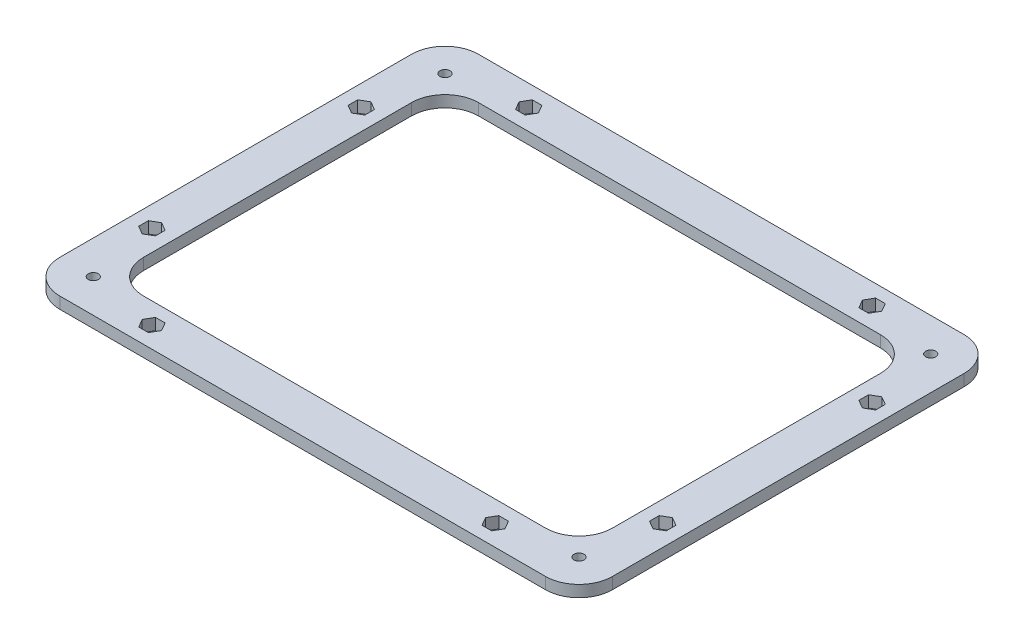
from build123d import *

# Parameters (mm, degrees)
SKETCH1_W           = 330
SKETCH1_H           = 250
BOSS_EXTRUDE1_DEPTH = 6.9
SKETCH2_R           = 3
CUT_EXTRUDE1_DEPTH  = 7.9
SKETCH3_W           = 280
SKETCH3_H           = 200
CUT_EXTRUDE2_DEPTH  = 7.9
FILLET1_R           = 20
FILLET2_R           = 20
CUT_EXTRUDE4_DEPTH  = 7.9


with BuildPart() as part:
    # Sketch1 → Boss-Extrude1 (new body)
    with BuildSketch(Plane(origin=(0, 0, 0), x_dir=(1, 0, 0), z_dir=(0, 1, 0))):
        Rectangle(SKETCH1_W, SKETCH1_H)
    extrude(amount=BOSS_EXTRUDE1_DEPTH)

    # Sketch2 → Cut-Extrude1 (cut, through all)
    with BuildSketch(Plane(origin=(0, 6.9, 0), x_dir=(1, 0, 0), z_dir=(0, 1, 0))):
        with Locations((-145, 105)):
            Circle(SKETCH2_R)
        with Locations((145, 105)):
            Circle(SKETCH2_R)
        with Locations((145, -105)):
            Circle(SKETCH2_R)
        with Locations((-145, -105)):
            Circle(SKETCH2_R)
    extrude(amount=-CUT_EXTRUDE1_DEPTH, mode=Mode.SUBTRACT)

    # Sketch3 → Cut-Extrude2 (cut, through all)
    with BuildSketch(Plane(origin=(0, 6.9, 0), x_dir=(1, 0, 0), z_dir=(0, 1, 0))):
        Rectangle(SKETCH3_W, SKETCH3_H)
    extrude(amount=-CUT_EXTRUDE2_DEPTH, mode=Mode.SUBTRACT)

    # Fillet1
    fillet1_edges = [part.edges().sort_by_distance(p)[0] for p in [
        (-165, 3.45, -125),
        (165, 3.45, -125),
        (165, 3.45, 125),
        (-165, 3.45, 125),
    ]]
    fillet(fillet1_edges, radius=FILLET1_R)

    # Fillet2
    fillet2_edges = [part.edges().sort_by_distance(p)[0] for p in [
        (-140, 3.45, 100),
        (-140, 3.45, -100),
        (140, 3.45, -100),
        (140, 3.45, 100),
    ]]
    fillet(fillet2_edges, radius=FILLET2_R)

    # Sketch4 → Cut-Extrude4 (cut, through all)
    with BuildSketch(Plane(origin=(0, 6.9, 0), x_dir=(1, 0, 0), z_dir=(0, 1, 0))):
        Polygon((-105.386751346, -107.5), (-99.613248654, -107.5), (-96.726497308, -112.5), (-99.613248654, -117.5), (-105.386751346, -117.5), (-108.273502692, -112.5), align=None)
        Polygon((-147.5, -59.613248654), (-152.5, -56.726497308), (-157.5, -59.613248654), (-157.5, -65.386751346), (-152.5, -68.273502692), (-147.5, -65.386751346), align=None)
        Polygon((99.613248654, -107.5), (96.726497308, -112.5), (99.613248654, -117.5), (105.386751346, -117.5), (108.273502692, -112.5), (105.386751346, -107.5), align=None)
        Polygon((147.5, -65.386751346), (147.5, -59.613248654), (152.5, -56.726497308), (157.5, -59.613248654), (157.5, -65.386751346), (152.5, -68.273502692), align=None)
        Polygon((147.5, 59.613248654), (152.5, 56.726497308), (157.5, 59.613248654), (157.5, 65.386751346), (152.5, 68.273502692), (147.5, 65.386751346), align=None)
        Polygon((105.386751346, 107.5), (99.613248654, 107.5), (96.726497308, 112.5), (99.613248654, 117.5), (105.386751346, 117.5), (108.273502692, 112.5), align=None)
        Polygon((-99.613248654, 107.5), (-96.726497308, 112.5), (-99.613248654, 117.5), (-105.386751346, 117.5), (-108.273502692, 112.5), (-105.386751346, 107.5), align=None)
        Polygon((-147.5, 65.386751346), (-147.5, 59.613248654), (-152.5, 56.726497308), (-157.5, 59.613248654), (-157.5, 65.386751346), (-152.5, 68.273502692), align=None)
    extrude(amount=-CUT_EXTRUDE4_DEPTH, mode=Mode.SUBTRACT)


solid = part.part
